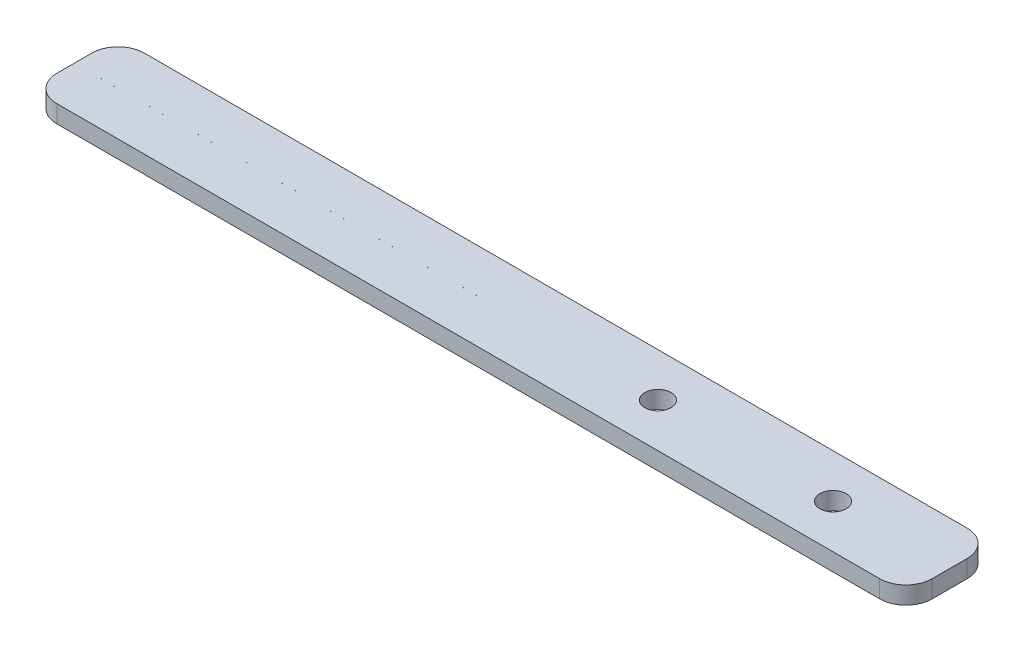
from build123d import *

# Parameters (mm, degrees)
SKETCH1_W             = 100
SKETCH1_H             = 10
BOSS_EXTRUDE1_DEPTH   = 2
FILLET1_R             = 3
F_3_0MM_DOWEL_HOLE1_D = 3
SKETCH2_W             = 47
SKETCH2_H             = 0.001
CUT_EXTRUDE1_DEPTH    = 10


with BuildPart() as part:
    # Sketch1 → Boss-Extrude1 (new body)
    with BuildSketch(Plane(origin=(0, 0, 0), x_dir=(1, 0, 0), z_dir=(0, 1, 0))):
        Rectangle(SKETCH1_W, SKETCH1_H)
    extrude(amount=BOSS_EXTRUDE1_DEPTH)

    # Fillet1
    fillet1_edges = [part.edges().sort_by_distance(p)[0] for p in [
        (50, 1, 5),
        (-50, 1, 5),
        (-50, 1, -5),
        (50, 1, -5),
    ]]
    fillet(fillet1_edges, radius=FILLET1_R)

    # Ø3.0mm Dowel Hole1 (through all)
    with Locations(Plane(origin=(0, 2, 0), x_dir=(1, 0, 0), z_dir=(0, 1, 0))):
        with Locations((36.669467955, 0), (16.669467955, 0)):
            Hole(F_3_0MM_DOWEL_HOLE1_D / 2)

    # Sketch2 → Cut-Extrude1 (cut)
    with BuildSketch(Plane(origin=(0, 2, 0), x_dir=(1, 0, 0), z_dir=(0, 1, 0))):
        with Locations((-26.5, 0)):
            Rectangle(SKETCH2_W, SKETCH2_H)
    extrude(amount=-CUT_EXTRUDE1_DEPTH, mode=Mode.SUBTRACT)


solid = part.part
